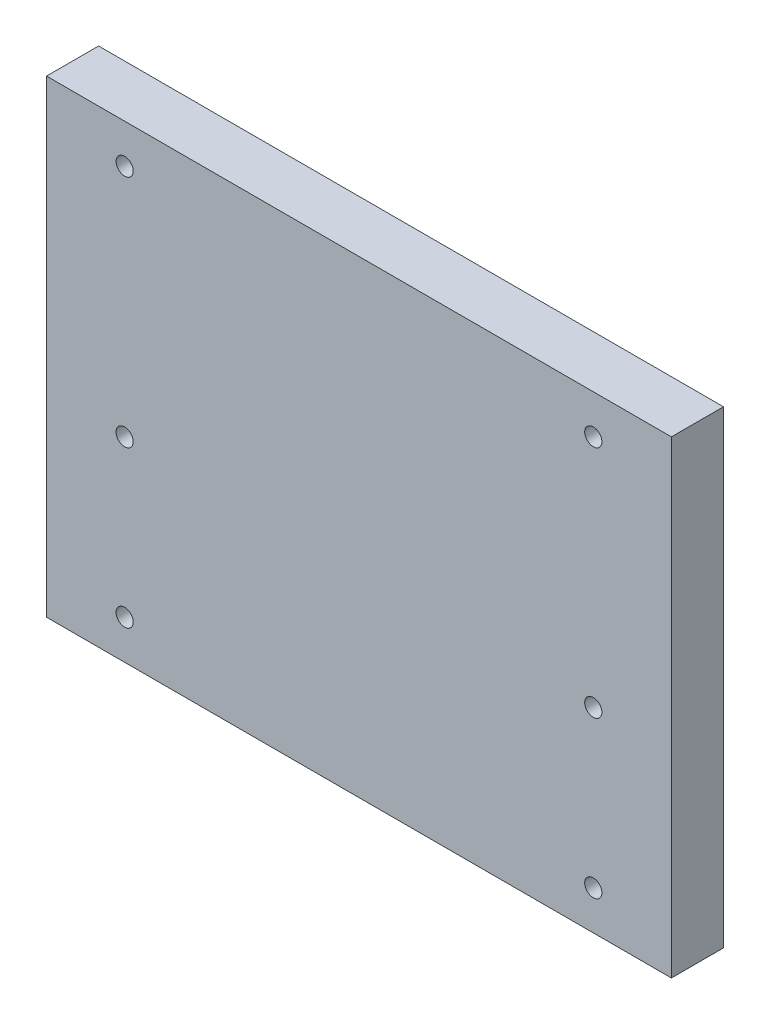
from build123d import *

# Parameters (mm, degrees)
SKETCH1_W                                           = 240
SKETCH1_H                                           = 180
EXTRUDE1_DEPTH                                      = 20
CBORE_FOR_M6_HEX_SOCKET_HEAD_CAP_SCREW1_D           = 6.6
CBORE_FOR_M6_HEX_SOCKET_HEAD_CAP_SCREW1_CBORE_D     = 11
CBORE_FOR_M6_HEX_SOCKET_HEAD_CAP_SCREW1_CBORE_DEPTH = 6.4


with BuildPart() as part:
    # Sketch1 → Extrude1 (new body)
    with BuildSketch(Plane.XY):
        Rectangle(SKETCH1_W, SKETCH1_H)
    extrude(amount=EXTRUDE1_DEPTH)

    # CBORE for M6 Hex Socket Head Cap Screw1 (through all)
    with Locations(Plane(origin=(0, 0, 0), x_dir=(-1, 0, 0), z_dir=(0, 0, -1))):
        with Locations((-90, 75), (-90, -75), (-90, -15), (90, -15), (90, -75), (90, 75)):
            CounterBoreHole(CBORE_FOR_M6_HEX_SOCKET_HEAD_CAP_SCREW1_D / 2, CBORE_FOR_M6_HEX_SOCKET_HEAD_CAP_SCREW1_CBORE_D / 2, CBORE_FOR_M6_HEX_SOCKET_HEAD_CAP_SCREW1_CBORE_DEPTH)


solid = part.part
